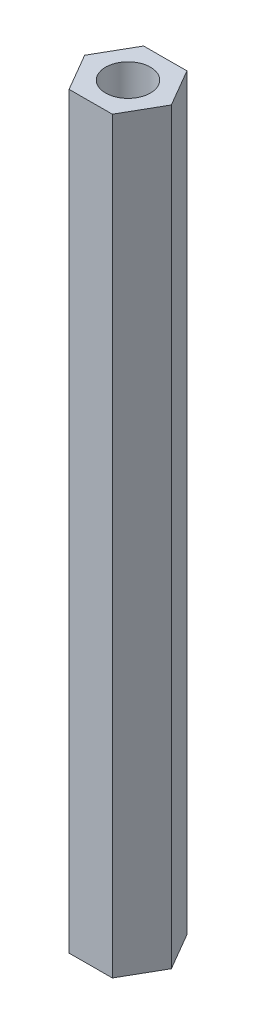
from build123d import *

# Parameters (mm, degrees)
Y_KSEKLIK_EKSTR_ZYON1_DEPTH = 50
IZIM2_R                     = 1.5
KES_EKSTR_ZYON1_DEPTH       = 50


with BuildPart() as part:
    # Çizim1 → Yükseklik-Ekstrüzyon1 (new body)
    with BuildSketch(Plane(origin=(0, 0, 0), x_dir=(1, 0, 0), z_dir=(0, 1, 0))):
        Polygon((1.435517753, 2.504520336), (-1.451219358, 2.49545501), (-2.886737112, -0.009065326), (-1.435517753, -2.504520336), (1.451219358, -2.49545501), (2.886737112, 0.009065326), align=None)
    extrude(amount=Y_KSEKLIK_EKSTR_ZYON1_DEPTH)

    # Çizim2 → Kes-Ekstrüzyon1 (cut)
    with BuildSketch(Plane(origin=(0, 50, 0), x_dir=(1, 0, 0), z_dir=(0, 1, 0))):
        Circle(IZIM2_R)
    extrude(amount=-KES_EKSTR_ZYON1_DEPTH, mode=Mode.SUBTRACT)


solid = part.part
